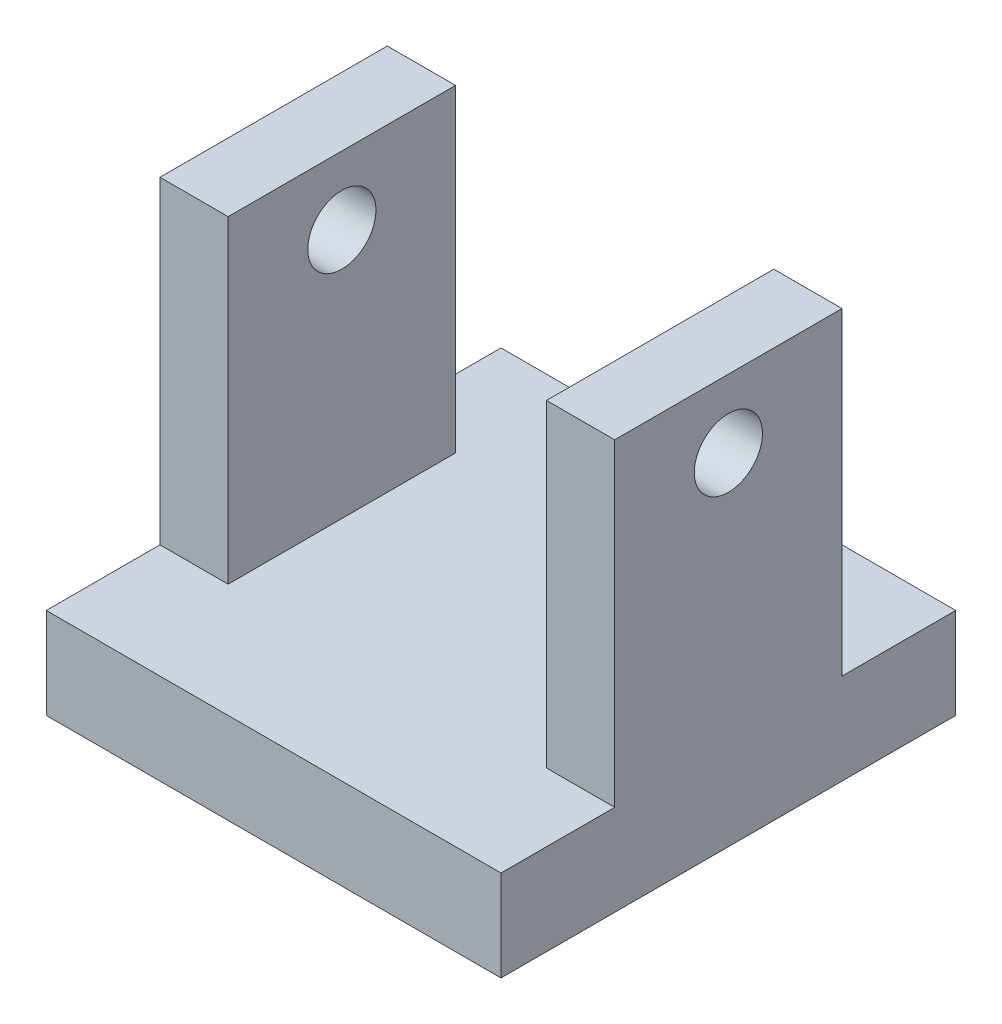
from build123d import *

# Parameters (mm, degrees)
SKETCH2_W           = 50
SKETCH2_H           = 50
BOSS_EXTRUDE1_DEPTH = 10
SKETCH3_W           = 7.5
SKETCH3_H           = 25
BOSS_EXTRUDE2_DEPTH = 35
SKETCH4_R           = 3.75
CUT_EXTRUDE1_DEPTH  = 50


with BuildPart() as part:
    # Sketch2 → Boss-Extrude1 (new body)
    with BuildSketch(Plane(origin=(0, 0, 0), x_dir=(1, 0, 0), z_dir=(0, 1, 0))):
        with Locations((25, 25)):
            Rectangle(SKETCH2_W, SKETCH2_H)
    extrude(amount=BOSS_EXTRUDE1_DEPTH)

    # Sketch3 → Boss-Extrude2 (add)
    with BuildSketch(Plane(origin=(0, 10, 0), x_dir=(1, 0, 0), z_dir=(0, 1, 0))):
        with Locations((3.75, 25)):
            Rectangle(SKETCH3_W, SKETCH3_H)
        with Locations((46.25, 25)):
            Rectangle(SKETCH3_W, SKETCH3_H)
    extrude(amount=BOSS_EXTRUDE2_DEPTH)

    # Sketch4 → Cut-Extrude1 (cut)
    with BuildSketch(Plane(origin=(50, 0, 0), x_dir=(0, 0, -1), z_dir=(1, 0, 0))):
        with Locations((25, 37.5)):
            Circle(SKETCH4_R)
    extrude(amount=-CUT_EXTRUDE1_DEPTH, mode=Mode.SUBTRACT)


solid = part.part
